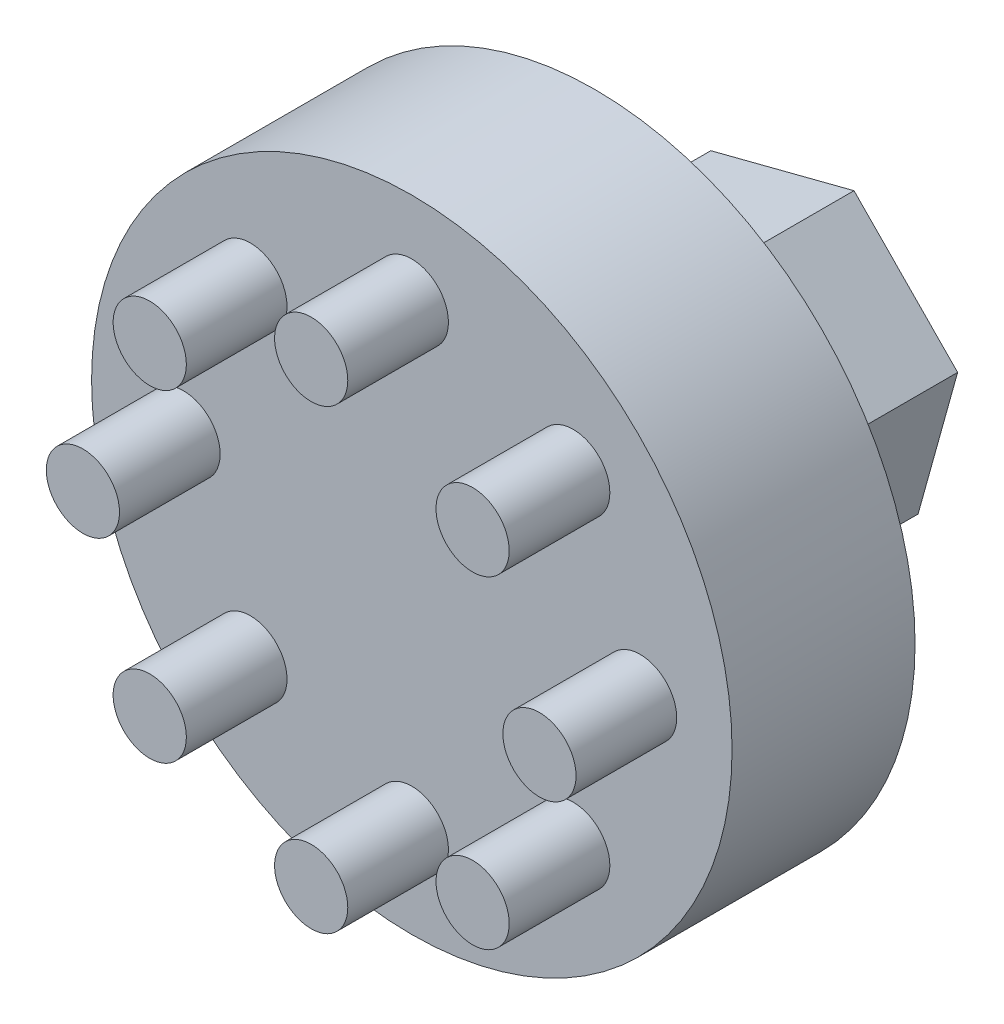
from build123d import *

# Parameters (mm, degrees)
ESQUISSE1_R        = 17.5
BOSS_EXTRU_1_DEPTH = 10
ESQUISSE2_R        = 2
BOSS_EXTRU_2_DEPTH = 5.5
BOSS_EXTRU_3_DEPTH = 12


with BuildPart() as part:
    # Esquisse1 → Boss.-Extru.1 (new body)
    with BuildSketch(Plane.XY):
        Circle(ESQUISSE1_R)
    extrude(amount=BOSS_EXTRU_1_DEPTH)

    # Esquisse2 → Boss.-Extru.2 (add)
    with BuildSketch(Plane.XY.offset(10)):
        with Locations((8.821157095, 8.821157095)):
            Circle(ESQUISSE2_R)
        with Locations((0, 12.475)):
            Circle(ESQUISSE2_R)
        with Locations((12.475, 0)):
            Circle(ESQUISSE2_R)
        with Locations((8.821157095, -8.821157095)):
            Circle(ESQUISSE2_R)
        with Locations((0, -12.475)):
            Circle(ESQUISSE2_R)
        with Locations((-8.821157095, -8.821157095)):
            Circle(ESQUISSE2_R)
        with Locations((-12.475, 0)):
            Circle(ESQUISSE2_R)
        with Locations((-8.821157095, 8.821157095)):
            Circle(ESQUISSE2_R)
    extrude(amount=BOSS_EXTRU_2_DEPTH)

    # Esquisse3 → Boss.-Extru.3 (add)
    with BuildSketch(Plane(origin=(0, 0, 0), x_dir=(-1, 0, 0), z_dir=(0, 0, -1))):
        Polygon((5.662793102, 5.767677835), (-2.163558975, 7.787961601), (-7.826352077, 2.020283765), (-5.662793102, -5.767677835), (2.163558975, -7.787961601), (7.826352077, -2.020283765), align=None)
    extrude(amount=BOSS_EXTRU_3_DEPTH)


solid = part.part
